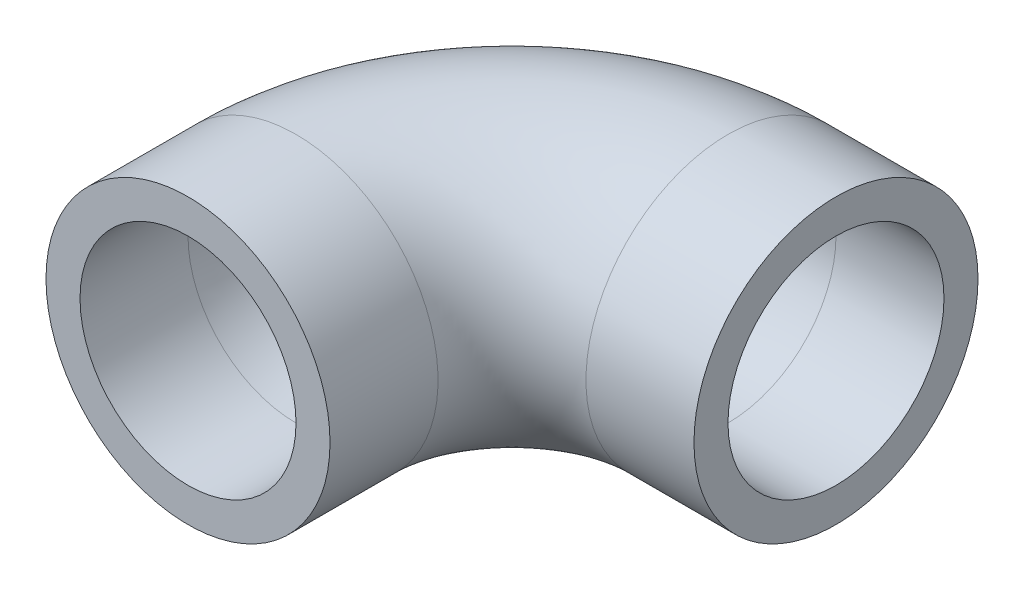
from build123d import *

# Parameters (mm, degrees)
SKETCH1_R   = 16.7005
SKETCH1_R_2 = 12.7


with BuildPart() as part:
    # Sweep1: sweep along a path in Sketch2
    with BuildLine(Plane(origin=(0, 0, 0), x_dir=(1, 0, 0), z_dir=(0, 1, 0))) as sweep1_path:
        Line((0, 0), (0, 12.7))
        ThreePointArc((0, 12.7), (7.439487758, 30.660512242), (25.4, 38.1))
        Line((25.4, 38.1), (38.1, 38.1))
    # Sketch1 → Sweep1 (sweep)
    with BuildSketch(Plane.XY):
        Circle(SKETCH1_R)
        Circle(SKETCH1_R_2, mode=Mode.SUBTRACT)
    sweep(path=sweep1_path.line)


solid = part.part
